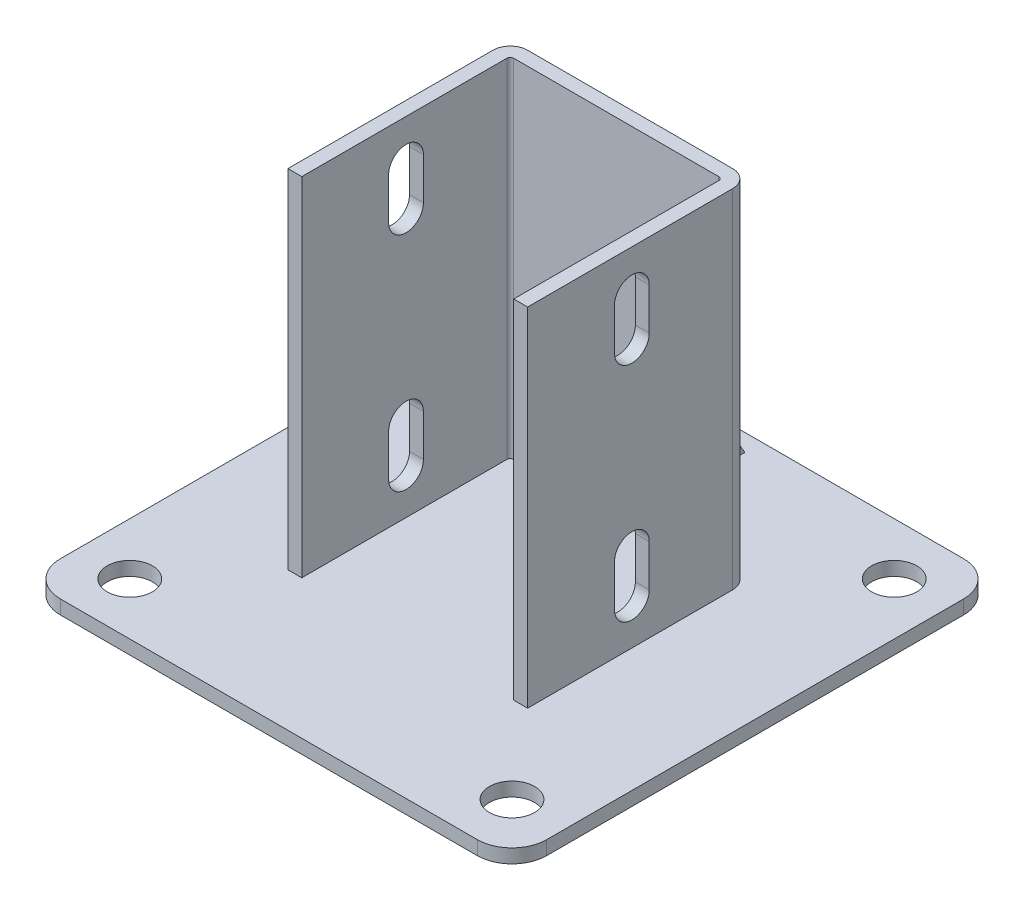
from build123d import *

# Parameters (mm, degrees)
SKETCH_2_W          = 140
SKETCH_2_H          = 140
EXTRUDE_1_DEPTH     = 4
EXTRUDE_1_2_DEPTH   = 100
EXTRUDE_2_DEPTH     = 2
CUT_EXTRUDE_1_DEPTH = 105.5
SKETCH_6_R          = 6.5
CUT_EXTRUDE_2_DEPTH = 5
FILLET_1_R          = 10


with BuildPart() as part:
    # Эскиз2 → Extrude 1 (new body)
    with BuildSketch(Plane(origin=(0, 0, 0), x_dir=(1, 0, 0), z_dir=(0, 1, 0))):
        Rectangle(SKETCH_2_W, SKETCH_2_H)
    extrude(amount=EXTRUDE_1_DEPTH)

    # Эскиз3 → Extrude 1 2 (add)
    with BuildSketch(Plane(origin=(0, 4, 0), x_dir=(1, 0, 0), z_dir=(0, 1, 0))):
        with BuildLine():
            Line((-30.5, -30), (-30.5, 29))
            ThreePointArc((-30.5, 29), (-30.207106781, 29.707106781), (-29.5, 30))
            Line((-29.5, 30), (29.5, 30))
            ThreePointArc((29.5, 30), (30.207106781, 29.707106781), (30.5, 29))
            Line((30.5, 29), (30.5, -30))
            Line((30.5, -30), (34.5, -30))
            Line((34.5, -30), (34.5, 29))
            ThreePointArc((34.5, 29), (33.035533906, 32.535533906), (29.5, 34))
            Line((29.5, 34), (-29.5, 34))
            ThreePointArc((-29.5, 34), (-33.035533906, 32.535533906), (-34.5, 29))
            Line((-34.5, 29), (-34.5, -30))
            Line((-34.5, -30), (-30.5, -30))
        make_face()
    extrude(amount=EXTRUDE_1_2_DEPTH)

    # Эскиз4 → Бобышка-Вытянуть2 (add, symmetric)
    with BuildSketch(Plane(origin=(0, 0, 0), x_dir=(0, 0, -1), z_dir=(1, 0, 0))):
        Polygon((34, 57.693575035), (65, 4), (34, 4), align=None)
    extrude(amount=EXTRUDE_2_DEPTH, both=True)

    # Эскиз5 → Вырез-Вытянуть1 (cut, through all)
    with BuildSketch(Plane(origin=(34.5, 0, 0), x_dir=(0, 0, -1), z_dir=(1, 0, 0))):
        with BuildLine():
            Line((5, 92), (5, 80))
            ThreePointArc((5, 80), (0, 75), (-5, 80))
            Line((-5, 80), (-5, 92))
            ThreePointArc((-5, 92), (0, 97), (5, 92))
        make_face()
        with BuildLine():
            Line((5, 28), (5, 16))
            ThreePointArc((5, 16), (0, 11), (-5, 16))
            Line((-5, 16), (-5, 28))
            ThreePointArc((-5, 28), (0, 33), (5, 28))
        make_face()
    extrude(amount=-CUT_EXTRUDE_1_DEPTH, mode=Mode.SUBTRACT)

    # Эскиз6 → Вырез-Вытянуть2 (cut, through all)
    with BuildSketch(Plane(origin=(0, 4, 0), x_dir=(1, 0, 0), z_dir=(0, 1, 0))):
        with Locations(Location((-55, 55, 0), (0, 0, 270))):  # turned: the seam where the file's is
            Circle(SKETCH_6_R)
        with Locations(Location((-55, -55, 0), (0, 0, 270))):  # turned: the seam where the file's is
            Circle(SKETCH_6_R)
        with Locations(Location((55, 55, 0), (0, 0, 270))):  # turned: the seam where the file's is
            Circle(SKETCH_6_R)
        with Locations(Location((55, -55, 0), (0, 0, 270))):  # turned: the seam where the file's is
            Circle(SKETCH_6_R)
    extrude(amount=-CUT_EXTRUDE_2_DEPTH, mode=Mode.SUBTRACT)

    # Скругление1
    fillet_1_edges = [part.edges().sort_by_distance(p)[0] for p in [
        (70, 2, 70),
        (-70, 2, 70),
        (-70, 2, -70),
        (70, 2, -70),
    ]]
    fillet(fillet_1_edges, radius=FILLET_1_R)


solid = part.part
